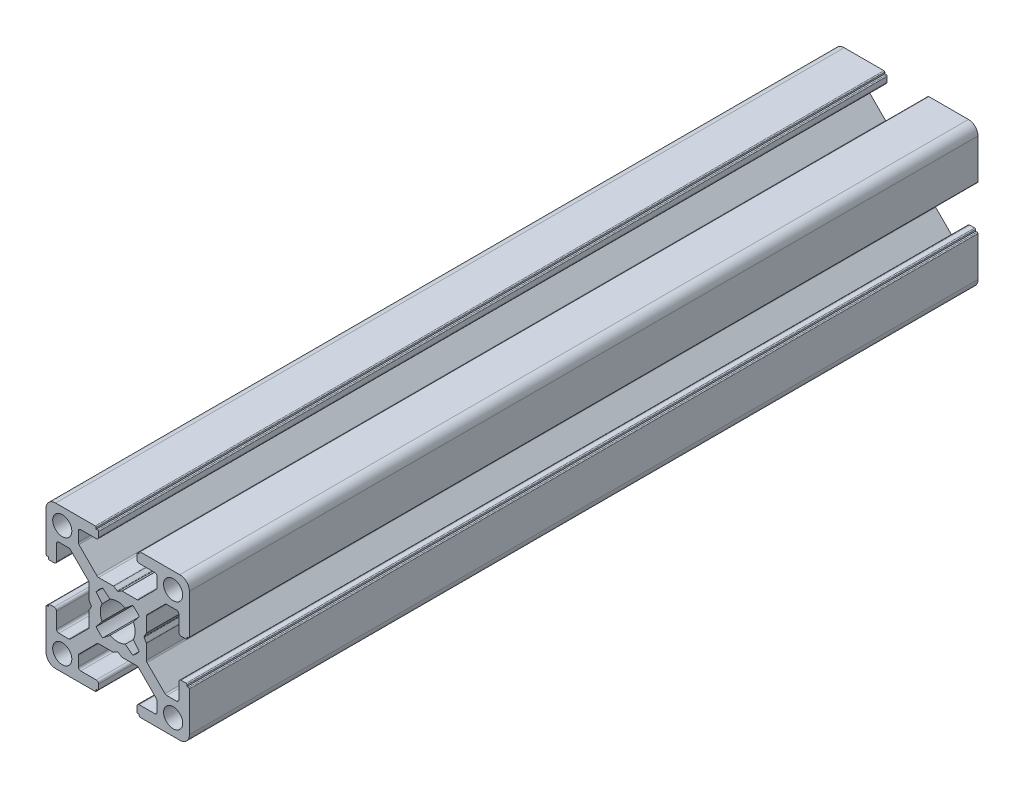
from build123d import *

# Parameters (mm, degrees)
CROQUIS1_R              = 2
SALIENTE_EXTRUIR1_DEPTH = 165


with BuildPart() as part:
    # Croquis1 → Saliente-Extruir1 (new body)
    with BuildSketch(Plane.XY.offset(1000)):
        with BuildLine():
            Line((9.800000436, -10.500000436), (10.100000436, -10.500000436))
            ThreePointArc((10.100000436, -10.500000436), (10.241421792, -10.441421792), (10.300000436, -10.300000436))
            Line((10.300000436, -10.300000436), (10.300000436, -2))
            ThreePointArc((10.300000436, -2), (9.714213998, -0.585786438), (8.300000436, 0))
            Line((8.300000436, 0), (0, 0))
            ThreePointArc((0, 0), (-0.141421356, -0.058578644), (-0.2, -0.2))
            Line((-0.2, -0.2), (-0.2, -0.5))
            Line((-0.2, -0.5), (-0.49999919, -0.5))
            ThreePointArc((-0.49999919, -0.5), (-0.641420811, -0.558578753), (-0.699999564, -0.700000374))
            Line((-0.699999564, -0.700000374), (-0.699999564, -1.700000763))
            ThreePointArc((-0.699999564, -1.700000763), (-0.553552955, -2.053554154), (-0.199999564, -2.200000763))
            Line((-0.199999564, -2.200000763), (3.050000763, -2.200000763))
            ThreePointArc((3.050000763, -2.200000763), (3.403554154, -2.346447372), (3.550000763, -2.700000763))
            Line((3.550000763, -2.700000763), (3.550000763, -4.743055509))
            ThreePointArc((3.550000763, -4.743055509), (3.511993279, -4.934269826), (3.403749103, -5.096413843))
            Line((3.403749103, -5.096413843), (-0.349053376, -8.853358334))
            ThreePointArc((-0.349053376, -8.853358334), (-0.511332616, -8.961886981), (-0.702801716, -9))
            Line((-0.702801716, -9), (-3.746809419, -9))
            ThreePointArc((-3.746809419, -9), (-3.798212795, -9.006718618), (-3.846162576, -9.026423071))
            Line((-3.846162576, -9.026423071), (-4.600646407, -9.458279719))
            ThreePointArc((-4.600646407, -9.458279719), (-4.699999564, -9.48470279), (-4.799352721, -9.458279719))
            Line((-4.799352721, -9.458279719), (-5.553836552, -9.026423071))
            ThreePointArc((-5.553836552, -9.026423071), (-5.601786333, -9.006718618), (-5.653189709, -9))
            Line((-5.653189709, -9), (-8.697197412, -9))
            ThreePointArc((-8.697197412, -9), (-8.888666513, -8.961886981), (-9.050945752, -8.853358334))
            Line((-9.050945752, -8.853358334), (-12.803748231, -5.096413843))
            ThreePointArc((-12.803748231, -5.096413843), (-12.911992407, -4.934269826), (-12.949999891, -4.743055509))
            Line((-12.949999891, -4.743055509), (-12.949999891, -2.700000763))
            ThreePointArc((-12.949999891, -2.700000763), (-12.803553282, -2.346447372), (-12.449999891, -2.200000763))
            Line((-12.449999891, -2.200000763), (-9.199999564, -2.200000763))
            ThreePointArc((-9.199999564, -2.200000763), (-8.846446173, -2.053554154), (-8.699999564, -1.700000763))
            Line((-8.699999564, -1.700000763), (-8.699999564, -0.700000374))
            ThreePointArc((-8.699999564, -0.700000374), (-8.758578317, -0.558578753), (-8.899999938, -0.5))
            Line((-8.899999938, -0.5), (-9.199999128, -0.5))
            Line((-9.199999128, -0.5), (-9.199999128, -0.2))
            ThreePointArc((-9.199999128, -0.2), (-9.258577772, -0.058578644), (-9.399999128, 0))
            Line((-9.399999128, 0), (-17.699999564, 0))
            ThreePointArc((-17.699999564, 0), (-19.114213126, -0.585786438), (-19.699999564, -2))
            Line((-19.699999564, -2), (-19.699999564, -10.300000436))
            ThreePointArc((-19.699999564, -10.300000436), (-19.64142092, -10.441421792), (-19.499999564, -10.500000436))
            Line((-19.499999564, -10.500000436), (-19.199999564, -10.500000436))
            Line((-19.199999564, -10.500000436), (-19.199999564, -10.799999627))
            ThreePointArc((-19.199999564, -10.799999627), (-19.141420811, -10.941421247), (-18.99999919, -11))
            Line((-18.99999919, -11), (-17.999998801, -11))
            ThreePointArc((-17.999998801, -11), (-17.64644541, -10.853553391), (-17.499998801, -10.5))
            Line((-17.499998801, -10.5), (-17.499998801, -7.249999673))
            ThreePointArc((-17.499998801, -7.249999673), (-17.353552192, -6.896446283), (-16.999998801, -6.749999673))
            Line((-16.999998801, -6.749999673), (-14.956944055, -6.749999673))
            ThreePointArc((-14.956944055, -6.749999673), (-14.765729738, -6.788007157), (-14.603585721, -6.896251334))
            Line((-14.603585721, -6.896251334), (-10.84664123, -10.649053813))
            ThreePointArc((-10.84664123, -10.649053813), (-10.738112583, -10.811333052), (-10.699999564, -11.002802152))
            Line((-10.699999564, -11.002802152), (-10.699999564, -14.046809855))
            ThreePointArc((-10.699999564, -14.046809855), (-10.693280947, -14.098213232), (-10.673576493, -14.146163012))
            Line((-10.673576493, -14.146163012), (-10.241719845, -14.900646843))
            ThreePointArc((-10.241719845, -14.900646843), (-10.215296774, -15), (-10.241719845, -15.099353157))
            Line((-10.241719845, -15.099353157), (-10.673576493, -15.853836988))
            ThreePointArc((-10.673576493, -15.853836988), (-10.693280947, -15.901786769), (-10.699999564, -15.953190146))
            Line((-10.699999564, -15.953190146), (-10.699999564, -18.997197848))
            ThreePointArc((-10.699999564, -18.997197848), (-10.738112583, -19.188666949), (-10.84664123, -19.350946188))
            Line((-10.84664123, -19.350946188), (-14.603585721, -23.103748667))
            ThreePointArc((-14.603585721, -23.103748667), (-14.765729738, -23.211992843), (-14.956944055, -23.250000327))
            Line((-14.956944055, -23.250000327), (-16.999998801, -23.250000327))
            ThreePointArc((-16.999998801, -23.250000327), (-17.353552192, -23.103553718), (-17.499998801, -22.750000327))
            Line((-17.499998801, -22.750000327), (-17.499998801, -19.5))
            ThreePointArc((-17.499998801, -19.5), (-17.64644541, -19.14644661), (-17.999998801, -19))
            Line((-17.999998801, -19), (-18.99999919, -19))
            ThreePointArc((-18.99999919, -19), (-19.141420811, -19.058578753), (-19.199999564, -19.200000374))
            Line((-19.199999564, -19.200000374), (-19.199999564, -19.499999564))
            Line((-19.199999564, -19.499999564), (-19.499999564, -19.499999564))
            ThreePointArc((-19.499999564, -19.499999564), (-19.64142092, -19.558578208), (-19.699999564, -19.699999564))
            Line((-19.699999564, -19.699999564), (-19.699999564, -28))
            ThreePointArc((-19.699999564, -28), (-19.114213126, -29.414213563), (-17.699999564, -30))
            Line((-17.699999564, -30), (-9.399999128, -30))
            ThreePointArc((-9.399999128, -30), (-9.258577772, -29.941421356), (-9.199999128, -29.8))
            Line((-9.199999128, -29.8), (-9.199999128, -29.5))
            Line((-9.199999128, -29.5), (-8.899999938, -29.5))
            ThreePointArc((-8.899999938, -29.5), (-8.758578317, -29.441421247), (-8.699999564, -29.299999627))
            Line((-8.699999564, -29.299999627), (-8.699999564, -28.299999237))
            ThreePointArc((-8.699999564, -28.299999237), (-8.846446173, -27.946445847), (-9.199999564, -27.799999237))
            Line((-9.199999564, -27.799999237), (-12.449999891, -27.799999237))
            ThreePointArc((-12.449999891, -27.799999237), (-12.803553282, -27.653552628), (-12.949999891, -27.299999237))
            Line((-12.949999891, -27.299999237), (-12.949999891, -25.256944491))
            ThreePointArc((-12.949999891, -25.256944491), (-12.911992407, -25.065730174), (-12.803748231, -24.903586157))
            Line((-12.803748231, -24.903586157), (-9.050945752, -21.146641666))
            ThreePointArc((-9.050945752, -21.146641666), (-8.888666513, -21.038113019), (-8.697197412, -21))
            Line((-8.697197412, -21), (-5.653189709, -21))
            ThreePointArc((-5.653189709, -21), (-5.601786333, -20.993281383), (-5.553836552, -20.973576929))
            Line((-5.553836552, -20.973576929), (-4.799352721, -20.541720281))
            ThreePointArc((-4.799352721, -20.541720281), (-4.699999564, -20.51529721), (-4.600646407, -20.541720281))
            Line((-4.600646407, -20.541720281), (-3.846162576, -20.973576929))
            ThreePointArc((-3.846162576, -20.973576929), (-3.798212795, -20.993281383), (-3.746809419, -21))
            Line((-3.746809419, -21), (-0.702801716, -21))
            ThreePointArc((-0.702801716, -21), (-0.511332616, -21.038113019), (-0.349053377, -21.146641666))
            Line((-0.349053377, -21.146641666), (3.403749103, -24.903586157))
            ThreePointArc((3.403749103, -24.903586157), (3.511993279, -25.065730174), (3.550000763, -25.256944491))
            Line((3.550000763, -25.256944491), (3.550000763, -27.299999237))
            ThreePointArc((3.550000763, -27.299999237), (3.403554154, -27.653552628), (3.050000763, -27.799999237))
            Line((3.050000763, -27.799999237), (-0.199999564, -27.799999237))
            ThreePointArc((-0.199999564, -27.799999237), (-0.553552955, -27.946445847), (-0.699999564, -28.299999237))
            Line((-0.699999564, -28.299999237), (-0.699999564, -29.299999627))
            ThreePointArc((-0.699999564, -29.299999627), (-0.641420811, -29.441421247), (-0.49999919, -29.5))
            Line((-0.49999919, -29.5), (-0.2, -29.5))
            Line((-0.2, -29.5), (-0.2, -29.8))
            ThreePointArc((-0.2, -29.8), (-0.141421356, -29.941421356), (0, -30))
            Line((0, -30), (8.300000436, -30))
            ThreePointArc((8.300000436, -30), (9.714213998, -29.414213563), (10.300000436, -28))
            Line((10.300000436, -28), (10.300000436, -19.699999564))
            ThreePointArc((10.300000436, -19.699999564), (10.241421792, -19.558578208), (10.100000436, -19.499999564))
            Line((10.100000436, -19.499999564), (9.800000436, -19.499999564))
            Line((9.800000436, -19.499999564), (9.800000436, -19.200000374))
            ThreePointArc((9.800000436, -19.200000374), (9.741421683, -19.058578753), (9.600000062, -19))
            Line((9.600000062, -19), (8.599999673, -19))
            ThreePointArc((8.599999673, -19), (8.246446283, -19.14644661), (8.099999673, -19.5))
            Line((8.099999673, -19.5), (8.099999673, -22.750000327))
            ThreePointArc((8.099999673, -22.750000327), (7.953553064, -23.103553718), (7.599999673, -23.250000327))
            Line((7.599999673, -23.250000327), (5.556944927, -23.250000327))
            ThreePointArc((5.556944927, -23.250000327), (5.36573061, -23.211992843), (5.203586593, -23.103748667))
            Line((5.203586593, -23.103748667), (1.446642102, -19.350946188))
            ThreePointArc((1.446642102, -19.350946188), (1.338113455, -19.188666949), (1.300000436, -18.997197848))
            Line((1.300000436, -18.997197848), (1.300000436, -15.953190145))
            ThreePointArc((1.300000436, -15.953190145), (1.293281819, -15.901786769), (1.273577365, -15.853836988))
            Line((1.273577365, -15.853836988), (0.841720717, -15.099353157))
            ThreePointArc((0.841720717, -15.099353157), (0.815297646, -15), (0.841720717, -14.900646843))
            Line((0.841720717, -14.900646843), (1.273577365, -14.146163012))
            ThreePointArc((1.273577365, -14.146163012), (1.293281819, -14.098213231), (1.300000436, -14.046809855))
            Line((1.300000436, -14.046809855), (1.300000436, -11.002802152))
            ThreePointArc((1.300000436, -11.002802152), (1.338113455, -10.811333052), (1.446642102, -10.649053813))
            Line((1.446642102, -10.649053813), (5.203586593, -6.896251334))
            ThreePointArc((5.203586593, -6.896251334), (5.36573061, -6.788007157), (5.556944927, -6.749999673))
            Line((5.556944927, -6.749999673), (7.599999673, -6.749999673))
            ThreePointArc((7.599999673, -6.749999673), (7.953553064, -6.896446283), (8.099999673, -7.249999673))
            Line((8.099999673, -7.249999673), (8.099999673, -10.5))
            ThreePointArc((8.099999673, -10.5), (8.246446283, -10.853553391), (8.599999673, -11))
            Line((8.599999673, -11), (9.600000062, -11))
            ThreePointArc((9.600000062, -11), (9.741421683, -10.941421247), (9.800000436, -10.799999627))
            Line((9.800000436, -10.799999627), (9.800000436, -10.500000436))
        make_face()
        with Locations((-16.300000272, -3.399999983)):
            Circle(CROQUIS1_R, mode=Mode.SUBTRACT)
        with Locations((6.900001145, -3.399999983)):
            Circle(CROQUIS1_R, mode=Mode.SUBTRACT)
        with Locations((-16.300000272, -26.600000017)):
            Circle(CROQUIS1_R, mode=Mode.SUBTRACT)
        with Locations((6.900001145, -26.600000017)):
            Circle(CROQUIS1_R, mode=Mode.SUBTRACT)
        with BuildLine():
            Line((-7.835928976, -10.481599097), (-6.300129088, -11.719438233))
            ThreePointArc((-6.300129088, -11.719438233), (-4.699999564, -11.35), (-3.09987004, -11.719438233))
            Line((-3.09987004, -11.719438233), (-1.564070152, -10.481599097))
            ThreePointArc((-1.564070152, -10.481599097), (-0.818997305, -11.10284444), (-0.194662672, -11.845330527))
            Line((-0.194662672, -11.845330527), (-1.419437832, -13.399870404))
            ThreePointArc((-1.419437832, -13.399870404), (-1.049999564, -15), (-1.419437832, -16.600129597))
            Line((-1.419437832, -16.600129597), (-0.194662672, -18.154669473))
            ThreePointArc((-0.194662672, -18.154669473), (-0.818997305, -18.897155561), (-1.564070152, -19.518400903))
            Line((-1.564070152, -19.518400903), (-3.09987004, -18.280561767))
            ThreePointArc((-3.09987004, -18.280561767), (-4.699999564, -18.65), (-6.300129088, -18.280561767))
            Line((-6.300129088, -18.280561767), (-7.835928976, -19.518400903))
            ThreePointArc((-7.835928976, -19.518400903), (-8.581001823, -18.897155561), (-9.205336456, -18.154669473))
            Line((-9.205336456, -18.154669473), (-7.980561295, -16.600129597))
            ThreePointArc((-7.980561295, -16.600129597), (-8.349999564, -15), (-7.980561296, -13.399870404))
            Line((-7.980561296, -13.399870404), (-9.205336456, -11.845330527))
            ThreePointArc((-9.205336456, -11.845330527), (-8.581001823, -11.10284444), (-7.835928976, -10.481599097))
        make_face(mode=Mode.SUBTRACT)
    extrude(amount=-SALIENTE_EXTRUIR1_DEPTH)


solid = part.part
